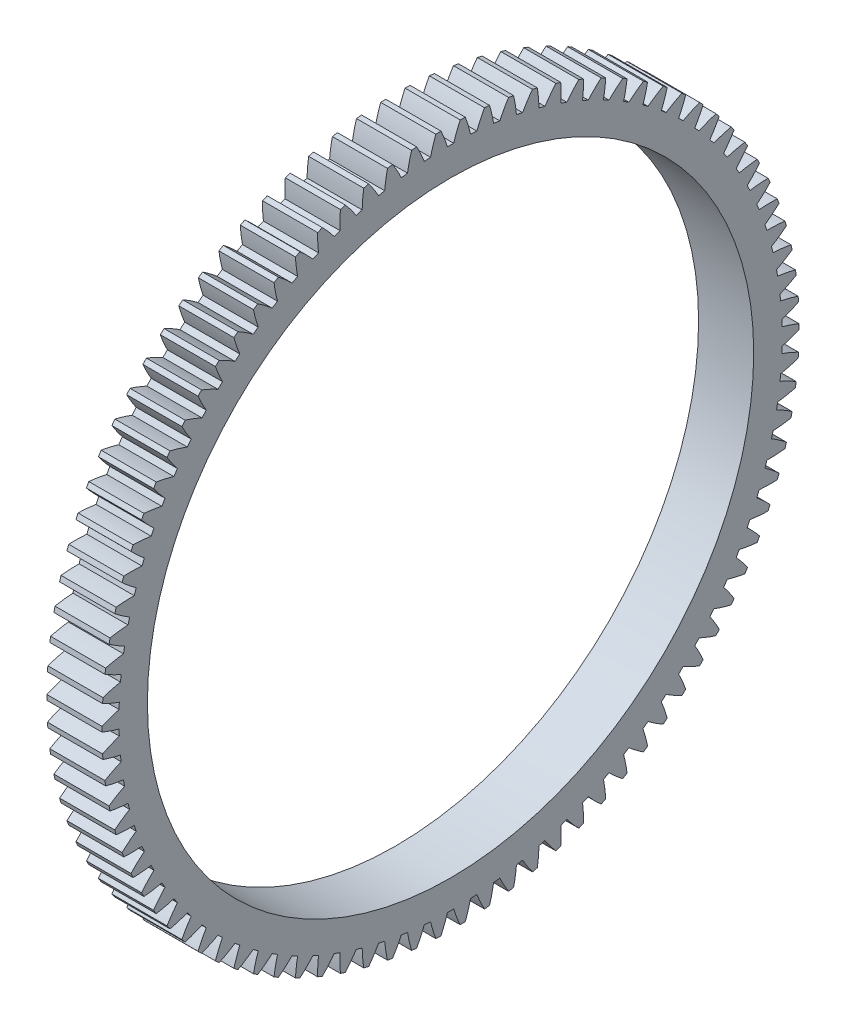
from build123d import *

# Parameters (mm, degrees)
BASPROSKE_W      = 10
BASPROSKE_H      = 63.25
TOOTHCUT_DEPTH   = 91.006249783
TEETHCUTS_COUNT  = 90
TEETHCUTS_ANGLE  = 356
HUBNEAONESKE_R   = 37.5
HUBNEARONE_DEPTH = 40.0000508
BORSKE_R         = 55
BORE_DEPTH       = 50.0000508


with BuildPart() as part:
    # BasProSke → Base-Revolve (revolve)
    with BuildSketch(Plane(origin=(0, 0, 0), x_dir=(1, 0, 0), z_dir=(0, 1, 0)), mode=Mode.PRIVATE) as base_revolve_sk:
        with Locations((5, 31.625)):
            Rectangle(BASPROSKE_W, BASPROSKE_H)
    revolve(base_revolve_sk.sketch.rotate(Axis((-10, 0, 0), (1, 0, 0)), 180), axis=Axis((-10, 0, 0), (1, 0, 0)))

    # TooCutSke → ToothCut (cut, through all)
    with BuildSketch(Plane(origin=(0, 0, 0), x_dir=(0, 0, -1), z_dir=(1, 0, 0))):
        with BuildLine():
            ThreePointArc((0.568376937, 60.152564785), (0, 60.15525), (-0.568376937, 60.152564785))
            ThreePointArc((-0.568376937, 60.152564785), (-1.11053989, 61.721726105), (-1.75668027, 63.251010423))
            ThreePointArc((-1.75668027, 63.251010423), (0, 63.2754), (1.75668027, 63.251010423))
            ThreePointArc((1.75668027, 63.251010423), (1.11053989, 61.721726105), (0.568376937, 60.152564785))
        make_face()
    toothcut = extrude(amount=TOOTHCUT_DEPTH, mode=Mode.SUBTRACT)

    # TeethCuts: ToothCut ×90 about axis
    teethcuts_axis = Axis((-10, 0, 0), (1, 0, 0))
    for i in range(1, TEETHCUTS_COUNT):
        add(toothcut.rotate(teethcuts_axis, i * TEETHCUTS_ANGLE / (TEETHCUTS_COUNT - 1)), mode=Mode.SUBTRACT)

    # HubNeaOneSke → HubNearOne (add)
    with BuildSketch(Plane.ZY):
        with Locations(Location((0, 0, 0), (0, 0, 180))):
            Circle(HUBNEAONESKE_R)
    extrude(amount=HUBNEARONE_DEPTH)

    # BorSke → Bore (cut, symmetric)
    with BuildSketch(Plane(origin=(0, 0, 0), x_dir=(0, 0, -1), z_dir=(1, 0, 0))):
        with Locations(Location((0, 0, 0), (0, 0, 180))):
            Circle(BORSKE_R)
    extrude(amount=BORE_DEPTH, both=True, mode=Mode.SUBTRACT)


solid = part.part
